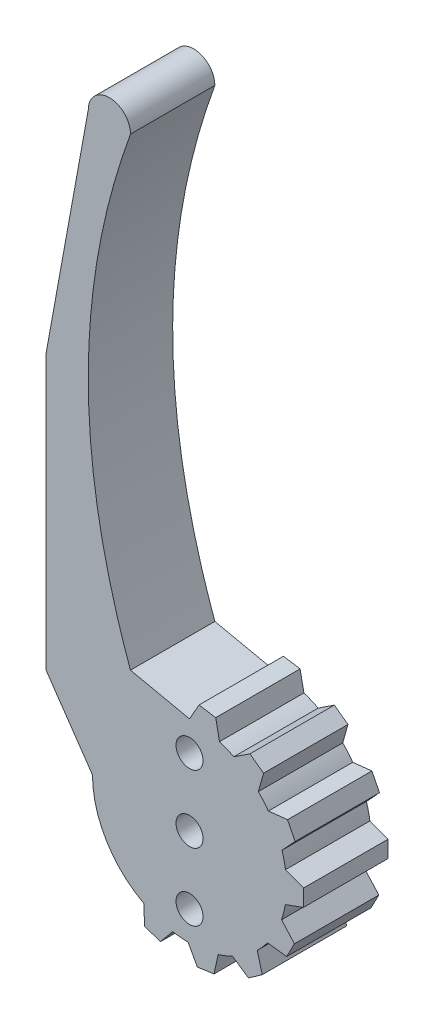
from build123d import *

# Parameters (mm, degrees)
SKETCH_1_R          = 11.5
EXTRUDE_1_DEPTH     = 10
SKETCH_2_R          = 1.6
CUT_EXTRUDE_1_DEPTH = 10


with BuildPart() as part:
    # 草圖1 → 填料-伸長1 (new body)
    with BuildSketch(Plane.XY):
        with BuildLine():
            ThreePointArc((0, 55), (-2.5, 57.5), (-5, 55))
            Line((-5, 55), (-10, 27.5))
            Line((-10, 27.5), (-10, -5))
            Line((-10, -5), (-4.5, -13))
            ThreePointArc((-4.5, -13), (-1.131727984, -4.868272016), (7, -1.5))
            Line((7, -1.5), (0, 0))
            add(Edge.make_bspline(
                [(0, 55), (-10, 27.5), (0, 0)],
                knots=[0, 0, 0, 1, 1, 1], degree=2))
        make_face()
        with Locations((7, -13)):
            Circle(SKETCH_1_R)
        with BuildLine():
            Line((8.124176937, 0.490227063), (7, -1.5))
            ThreePointArc((7, -1.5), (8.798996348, -1.641584083), (10.553695435, -2.062850063))
            Line((10.553695435, -2.062850063), (10.099553619, 0.177358133))
            Line((10.099553619, 0.177358133), (8.124176937, 0.490227063))
        make_face()
        with BuildLine():
            Line((14.154758721, -1.508288742), (12.24642256, -2.766474199))
            ThreePointArc((12.24642256, -2.766474199), (13.782706526, -3.713187189), (15.151977747, -4.888572333))
            Line((15.151977747, -4.888572333), (15.769856601, -2.687889877))
            Line((15.769856601, -2.687889877), (14.154758721, -1.508288742))
        make_face()
        with BuildLine():
            Line((18.609459232, -6.037927296), (16.337287066, -6.286947769))
            ThreePointArc((16.337287066, -6.286947769), (17.272482302, -7.830270089), (17.954734932, -9.500888316))
            Line((17.954734932, -9.500888316), (19.508542695, -7.824445957))
            Line((19.508542695, -7.824445957), (18.609459232, -6.037927296))
        make_face()
        with BuildLine():
            Line((20.507102251, -12.101006797), (18.371554502, -11.286013939))
            ThreePointArc((18.371554502, -11.286013939), (18.467843668, -12.140603924), (18.5, -13))
            ThreePointArc((18.5, -13), (18.461094648, -13.945150505), (18.34464183, -14.883905981))
            Line((18.34464183, -14.883905981), (20.492142426, -14.100950847))
            Line((20.492142426, -14.100950847), (20.507102251, -12.101006797))
        make_face()
        with BuildLine():
            ThreePointArc((17.901164481, -16.662596478), (17.193996736, -18.322821671), (16.23581896, -19.85198133))
            Line((16.23581896, -19.85198133), (18.504011675, -20.134964287))
            Line((18.504011675, -20.134964287), (19.429719792, -18.362095289))
            Line((19.429719792, -18.362095289), (17.901164481, -16.662596478))
        make_face()
        with BuildLine():
            ThreePointArc((15.029723408, -21.232468766), (13.643022341, -22.387238901), (12.092748017, -23.310864059))
            Line((12.092748017, -23.310864059), (13.98204893, -24.597456304))
            Line((13.98204893, -24.597456304), (15.614612218, -23.442148071))
            Line((15.614612218, -23.442148071), (15.029723408, -21.232468766))
        make_face()
        with BuildLine():
            ThreePointArc((10.389684506, -23.989087267), (8.628879877, -24.384056849), (6.827966819, -24.498713171))
            Line((6.827966819, -24.498713171), (7.922245347, -26.505534551))
            Line((7.922245347, -26.505534551), (9.902081321, -26.222251095))
            Line((9.902081321, -26.222251095), (10.389684506, -23.989087267))
        make_face()
        with BuildLine():
            ThreePointArc((5.003045957, -24.32528916), (3.255966224, -23.873463619), (1.601077028, -23.153897318))
            Line((1.601077028, -23.153897318), (1.659311339, -25.438932616))
            Line((1.659311339, -25.438932616), (3.55034849, -26.090068925))
            Line((3.55034849, -26.090068925), (5.003045957, -24.32528916))
        make_face()
    extrude(amount=EXTRUDE_1_DEPTH)

    # 草圖2 → 除料-伸長1 (cut)
    with BuildSketch(Plane.XY.offset(10)):
        with Locations((7, -5)):
            Circle(SKETCH_2_R)
        with Locations((7, -21)):
            Circle(SKETCH_2_R)
        with Locations((7, -13)):
            Circle(SKETCH_2_R)
    extrude(amount=-CUT_EXTRUDE_1_DEPTH, mode=Mode.SUBTRACT)


solid = part.part
